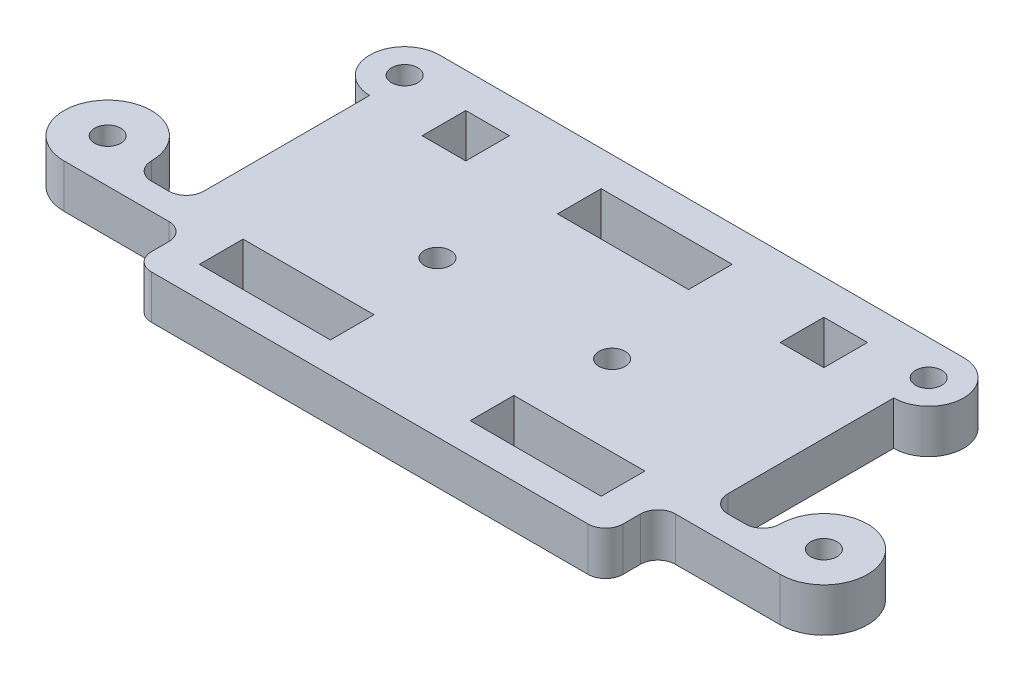
from build123d import *

# Parameters (mm, degrees)
SKETCH1_R           = 1.5
SKETCH1_W           = 5
SKETCH1_H           = 5
SKETCH1_W_2         = 15
BOSS_EXTRUDE1_DEPTH = 5


with BuildPart() as part:
    # Sketch1 → Boss-Extrude1 (new body)
    with BuildSketch(Plane(origin=(0, 0, 0), x_dir=(1, 0, 0), z_dir=(0, 1, 0))):
        with BuildLine():
            Line((-29, -11.75), (-30, -11.75))
            Line((-30, -11.75), (-41, -11.75))
            ThreePointArc((-41, -11.75), (-44.535533906, -3.214466094), (-36, -6.75))
            ThreePointArc((-36, -6.75), (-35.414213562, -8.164213562), (-34, -8.75))
            Line((-34, -8.75), (-32, -8.75))
            ThreePointArc((-32, -8.75), (-30.585786438, -8.164213562), (-30, -6.75))
            Line((-30, -6.75), (-30, 12.25))
            ThreePointArc((-30, 12.25), (-34, 16.25), (-30, 20.25))
            Line((-30, 20.25), (30, 20.25))
            ThreePointArc((30, 20.25), (34, 16.25), (30, 12.25))
            Line((30, 12.25), (30, -6.75))
            ThreePointArc((30, -6.75), (30.585786438, -8.164213562), (32, -8.75))
            Line((32, -8.75), (34, -8.75))
            ThreePointArc((34, -8.75), (35.414213562, -8.164213562), (36, -6.75))
            ThreePointArc((36, -6.75), (44.535533906, -3.214466094), (41, -11.75))
            Line((41, -11.75), (30, -11.75))
            Line((30, -11.75), (29, -11.75))
            ThreePointArc((29, -11.75), (27.585786438, -12.335786438), (27, -13.75))
            Line((27, -13.75), (27, -15.75))
            ThreePointArc((27, -15.75), (26.414213562, -17.164213562), (25, -17.75))
            Line((25, -17.75), (-25, -17.75))
            ThreePointArc((-25, -17.75), (-26.414213562, -17.164213562), (-27, -15.75))
            Line((-27, -15.75), (-27, -13.75))
            ThreePointArc((-27, -13.75), (-27.585786438, -12.335786438), (-29, -11.75))
        make_face()
        with Locations((-10, 0)):
            Circle(SKETCH1_R, mode=Mode.SUBTRACT)
        with Locations((10, 0)):
            Circle(SKETCH1_R, mode=Mode.SUBTRACT)
        with Locations((-30, 16.25)):
            Circle(SKETCH1_R, mode=Mode.SUBTRACT)
        with Locations((30, 16.25)):
            Circle(SKETCH1_R, mode=Mode.SUBTRACT)
        with Locations((41, -6.75)):
            Circle(SKETCH1_R, mode=Mode.SUBTRACT)
        with Locations((-41, -6.75)):
            Circle(SKETCH1_R, mode=Mode.SUBTRACT)
        with Locations((-20.5, 13.75)):
            Rectangle(SKETCH1_W, SKETCH1_H, mode=Mode.SUBTRACT)
        with Locations((0, 13.75)):
            Rectangle(SKETCH1_W_2, SKETCH1_H, mode=Mode.SUBTRACT)
        with Locations((20.5, 13.75)):
            Rectangle(SKETCH1_W, SKETCH1_H, mode=Mode.SUBTRACT)
        with Locations((-15.5, -11.75)):
            Rectangle(SKETCH1_W_2, SKETCH1_H, mode=Mode.SUBTRACT)
        with Locations((15.5, -11.75)):
            Rectangle(SKETCH1_W_2, SKETCH1_H, mode=Mode.SUBTRACT)
    extrude(amount=BOSS_EXTRUDE1_DEPTH)


solid = part.part
